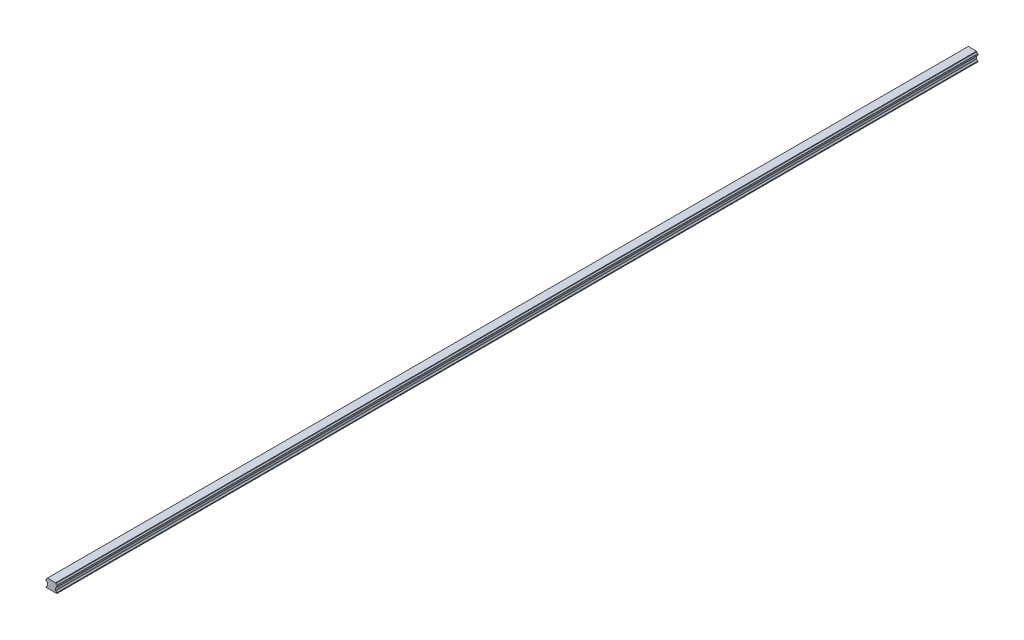
from build123d import *

# Parameters (mm, degrees)
ESTRUSIONE_ESTRUSIONE1_DEPTH = 1900


with BuildPart() as part:
    # Schizzo1 → Estrusione-Estrusione1 (new body)
    with BuildSketch(Plane.XY):
        with BuildLine():
            Line((-10.001211602, -16.276222172), (-7.501211602, -13.776222172))
            Line((-7.501211602, -13.776222172), (-7.501211602, -8.776222172))
            Line((-7.501211602, -8.776222172), (-8.008796188, -8.268637585))
            ThreePointArc((-8.008796188, -8.268637585), (-8.733444649, -6.695460987), (-10.306621247, -5.970812526))
            Line((-10.306621247, -5.970812526), (-10.501211602, -5.776222172))
            Line((-10.501211602, -5.776222172), (-10.501211602, -2.776222172))
            Line((-10.501211602, -2.776222172), (-10.306621247, -2.581631817))
            ThreePointArc((-10.306621247, -2.581631817), (-8.733444649, -1.856983356), (-8.008796188, -0.283806758))
            Line((-8.008796188, -0.283806758), (-7.501211602, 0.223777828))
            Line((-7.501211602, 0.223777828), (9.498788398, 0.223777828))
            Line((9.498788398, 0.223777828), (10.006372984, -0.283806758))
            ThreePointArc((10.006372984, -0.283806758), (10.731021445, -1.856983356), (12.304198043, -2.581631817))
            Line((12.304198043, -2.581631817), (12.498788398, -2.776222172))
            Line((12.498788398, -2.776222172), (12.498788398, -5.776222172))
            Line((12.498788398, -5.776222172), (12.304198043, -5.970812526))
            ThreePointArc((12.304198043, -5.970812526), (10.731021445, -6.695460987), (10.006372984, -8.268637585))
            Line((10.006372984, -8.268637585), (9.498788398, -8.776222172))
            Line((9.498788398, -8.776222172), (9.498788398, -13.776222172))
            Line((9.498788398, -13.776222172), (11.998788398, -16.276222172))
            Line((11.998788398, -16.276222172), (11.998788398, -17.776222172))
            Line((11.998788398, -17.776222172), (-10.001211602, -17.776222172))
            Line((-10.001211602, -17.776222172), (-10.001211602, -16.276222172))
        make_face()
    extrude(amount=ESTRUSIONE_ESTRUSIONE1_DEPTH)


solid = part.part
